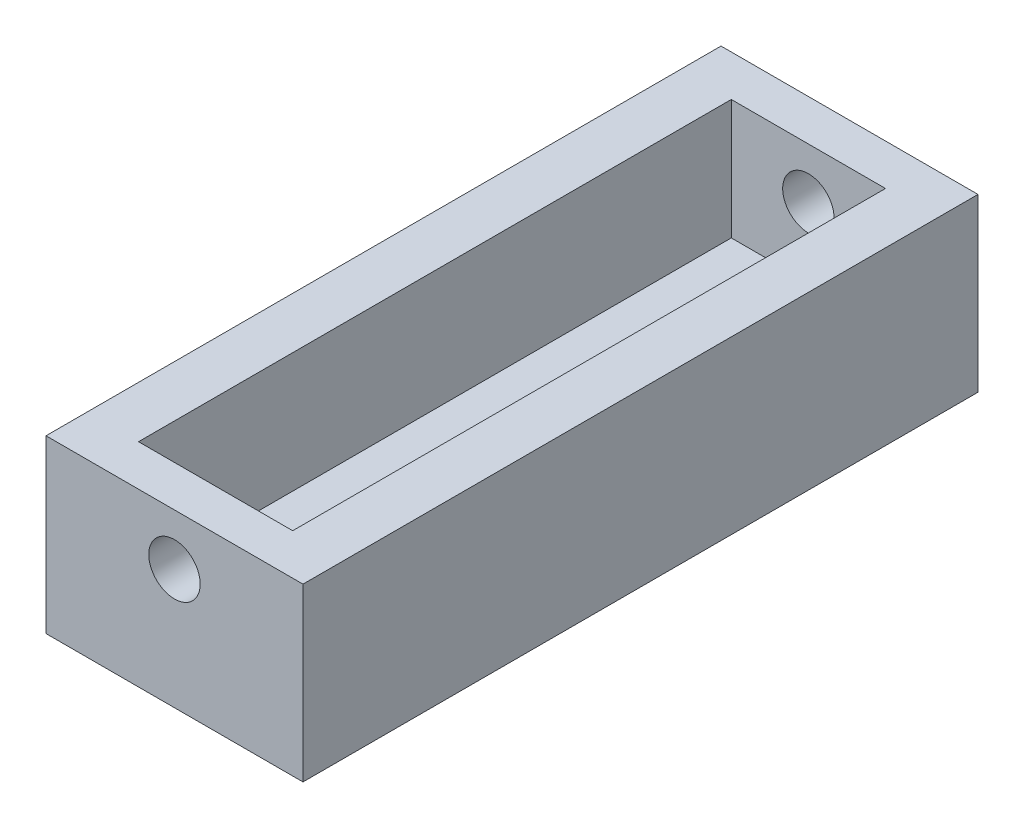
from build123d import *

# Parameters (mm, degrees)
BODY_DEPTH        = 17.3
BODY_2_DEPTH      = 17.3
SKETCH2_W         = 7.5
SKETCH2_H         = 5
END_DEPTH         = 1.2
END1_START        = 17.3
SKETCH2_4_W       = 7.5
SKETCH2_4_H       = 5
END1_DEPTH        = 1.2
SKETCH3_R         = 0.75
TENDON_HOLE_DEPTH = 19.7


with BuildPart() as part:
    # Sketch1 → body (new body)
    with BuildSketch(Plane.XY):
        Polygon((3.75, 0), (3.75, 5), (2.25, 5), (2.25, 1.5), (0.6, 1.5), (0.6, 0), align=None)
    extrude(amount=BODY_DEPTH)



with BuildPart() as body_2_2:
    # Sketch1 → body 2 (new body)
    with BuildSketch(Plane.XY):
        Polygon((-2.25, 1.5), (-2.25, 5), (-3.75, 5), (-3.75, 0), (-0.6, 0), (-0.6, 1.5), align=None)
    extrude(amount=BODY_2_DEPTH)


with BuildPart() as part_1:
    add(part.part)

    add(body_2_2.part)  # end merges body 2 2
    # Sketch2 → end (add)
    with BuildSketch(Plane.XY):
        with Locations((0, 2.5)):
            Rectangle(SKETCH2_W, SKETCH2_H)
    extrude(amount=-END_DEPTH)

    # Sketch2_4 → end1 (add)
    with BuildSketch(Plane.XY.offset(END1_START)):
        with Locations((0, 2.5)):
            Rectangle(SKETCH2_4_W, SKETCH2_4_H)
    extrude(amount=END1_DEPTH)

    # Sketch3 → tendon hole (cut)
    with BuildSketch(Plane.XY.offset(18.5)):
        with Locations((0, 3.5)):
            Circle(SKETCH3_R)
    extrude(amount=-TENDON_HOLE_DEPTH, mode=Mode.SUBTRACT)


solid = part_1.part
